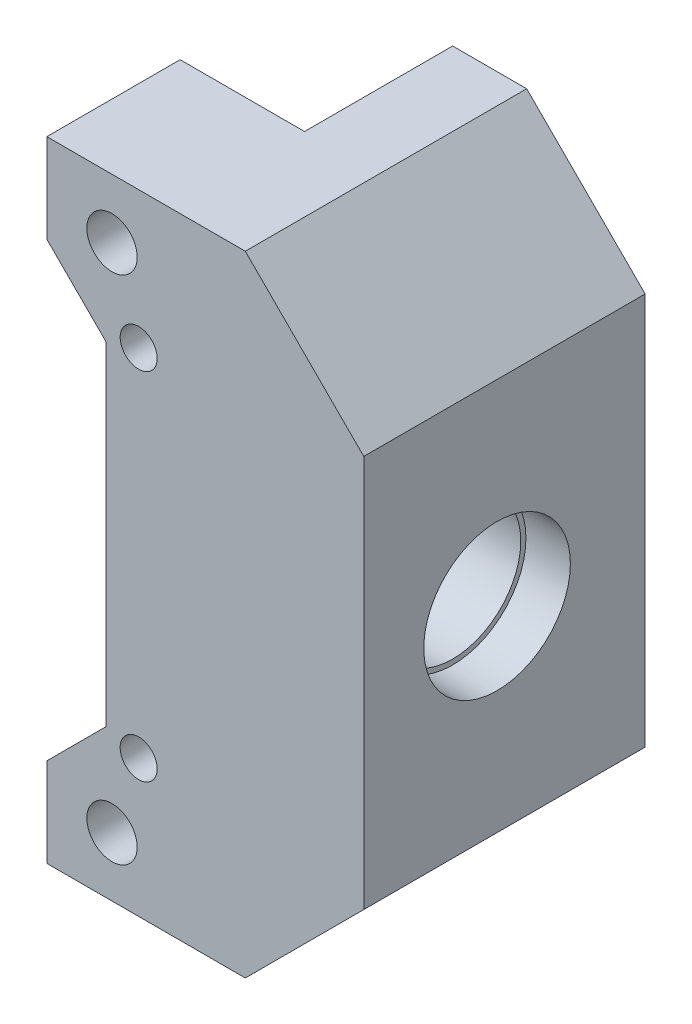
from build123d import *

# Parameters (mm, degrees)
ESQUISSE1_R                               = 1.7
BOSS_EXTRU_1_DEPTH                        = 9
ESQUISSE2_W                               = 13.000000001
ESQUISSE2_H                               = 42.5
BOSS_EXTRU_2_DEPTH                        = 19
ESQUISSE4_R                               = 6.025
ENL_V_MAT_EXTRU_1_DEPTH                   = 4.4
ENL_V_MAT_EXTRU_2_DEPTH                   = 5
ESQUISSE6_R                               = 4.6
ENL_V_MAT_EXTRU_3_DEPTH                   = 9
CHANFREIN1_SIZE                           = 8
TROU_POUR_TARAUDAGE_POUR_TROU_TARAUD_M3_D = 2.5
ESQUISSE9_R                               = 4.95
ENL_V_MAT_EXTRU_4_DEPTH                   = 3


with BuildPart() as part:
    # Esquisse1 → Boss.-Extru.1 (new body)
    with BuildSketch(Plane.XY):
        Polygon((38.615489841, 27.325), (38.615489841, 15.175), (38.61548984, 0), (30.21548984, 0), (30.21548984, 6), (34.21548984, 10), (34.215489841, 15.175), (34.215489841, 27.325), (34.21548984, 32.5), (30.21548984, 36.5), (30.21548984, 42.5), (38.61548984, 42.5), align=None)
        with Locations((34.61548984, 4)):
            Circle(ESQUISSE1_R, mode=Mode.SUBTRACT)
        with Locations((34.61548984, 38.5)):
            Circle(ESQUISSE1_R, mode=Mode.SUBTRACT)
    extrude(amount=BOSS_EXTRU_1_DEPTH)

    # Esquisse2 → Boss.-Extru.2 (add)
    with BuildSketch(Plane.XY.offset(9)):
        with Locations((45.115489841, 21.25)):
            Rectangle(ESQUISSE2_W, ESQUISSE2_H)
    extrude(amount=-BOSS_EXTRU_2_DEPTH)

    # Esquisse4 → Enlèv. mat.-Extru.1 (cut)
    with BuildSketch(Plane.ZY.offset(-34.215489841)):
        with Locations((0, 21.25)):
            Circle(ESQUISSE4_R)
    extrude(amount=-ENL_V_MAT_EXTRU_1_DEPTH, mode=Mode.SUBTRACT)

    # Esquisse5 → Enlèv. mat.-Extru.2 (cut)
    with BuildSketch(Plane.ZY.offset(-38.61548984)):
        with BuildLine():
            Line((0, 29.275), (-10, 29.275))
            Line((-10, 29.275), (-10, 13.225))
            Line((-10, 13.225), (0, 13.225))
            ThreePointArc((0, 13.225), (8.025, 21.25), (0, 29.275))
        make_face()
    extrude(amount=-ENL_V_MAT_EXTRU_2_DEPTH, mode=Mode.SUBTRACT)

    # Esquisse6 → Enlèv. mat.-Extru.3 (cut, through all)
    with BuildSketch(Plane.ZY.offset(-43.61548984)):
        with Locations((0, 21.25)):
            Circle(ESQUISSE6_R)
    extrude(amount=-ENL_V_MAT_EXTRU_3_DEPTH, mode=Mode.SUBTRACT)

    # Chanfrein1
    chanfrein1_edges = [part.edges().sort_by_distance(p)[0] for p in [
        (51.615489841, 0, -0.5),
        (51.615489841, 42.5, -0.5),
    ]]
    chamfer(chanfrein1_edges, length=CHANFREIN1_SIZE)

    # Trou pour taraudage pour trou taraudé M31 (through all)
    with Locations(Plane.XY.offset(9)):
        with Locations((36.41548984, 33.25), (36.41548984, 9.25)):
            Hole(TROU_POUR_TARAUDAGE_POUR_TROU_TARAUD_M3_D / 2)

    # Esquisse9 → Enlèv. mat.-Extru.4 (cut)
    with BuildSketch(Plane(origin=(51.615489841, 0, 0), x_dir=(0, 0, -1), z_dir=(1, 0, 0))):
        with Locations((0, 21.25)):
            Circle(ESQUISSE9_R)
    extrude(amount=-ENL_V_MAT_EXTRU_4_DEPTH, mode=Mode.SUBTRACT)


solid = part.part
